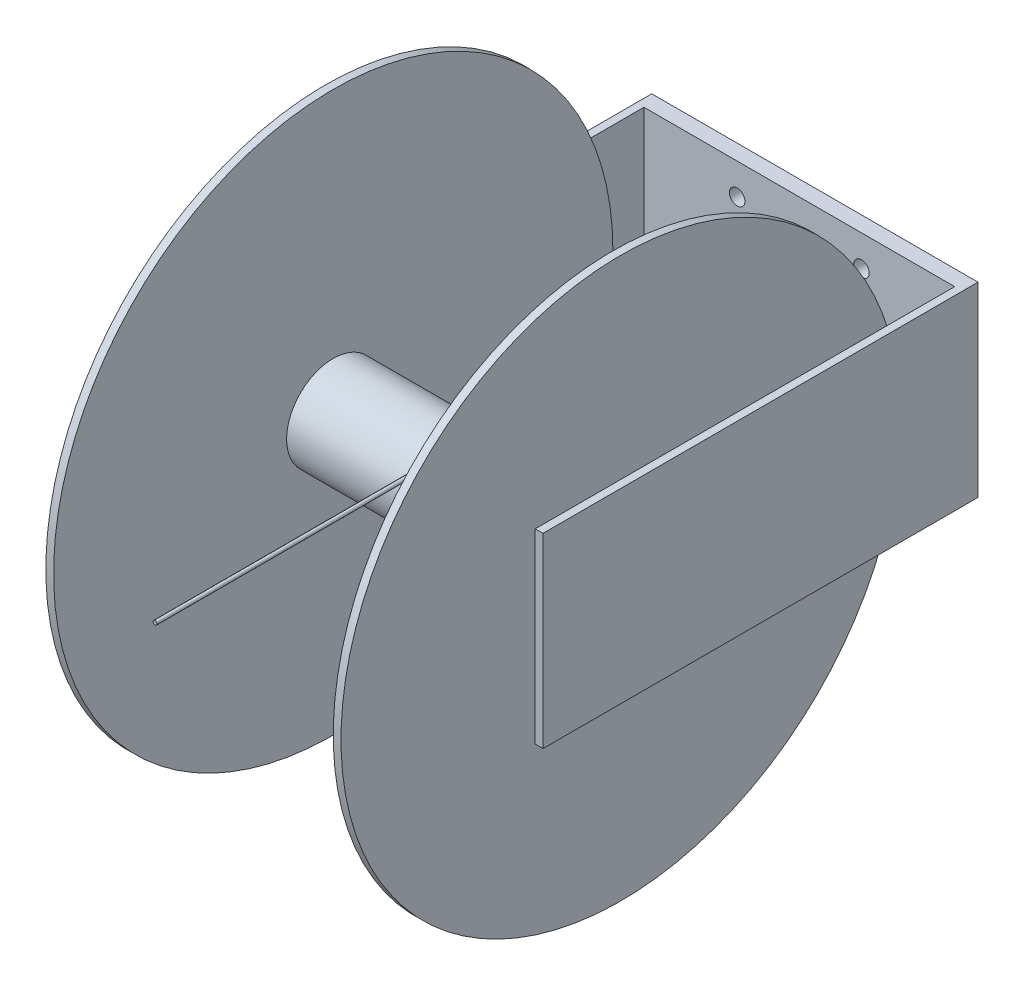
from build123d import *

# Parameters (mm, degrees)
SKETCH1_R           = 228.6
BOSS_EXTRUDE1_DEPTH = 6.35
SKETCH2_R           = 38.1
BOSS_EXTRUDE2_DEPTH = 228.6
SKETCH3_R           = 228.6
BOSS_EXTRUDE3_DEPTH = 6.35
SKETCH4_R           = 38.1
BOSS_EXTRUDE4_DEPTH = 6.35
SKETCH5_R           = 38.1
BOSS_EXTRUDE5_DEPTH = 6.35
BOSS_EXTRUDE6_DEPTH = 6.35
SKETCH7_W           = 203.2
SKETCH7_H           = 152.4
BOSS_EXTRUDE7_DEPTH = 6.35
BOSS_EXTRUDE8_DEPTH = 6.35
SKETCH9_W           = 12.7
SKETCH9_H           = 151.635108104
BOSS_EXTRUDE9_DEPTH = 254
SKETCH10_R          = 6.35
CUT_EXTRUDE1_DEPTH  = 12.7
SKETCH13_R          = 1.59


with BuildPart() as part:
    # Sketch1 → Boss-Extrude1 (new body)
    with BuildSketch(Plane(origin=(0, 0, 0), x_dir=(0, 0, -1), z_dir=(1, 0, 0))):
        Circle(SKETCH1_R)
    extrude(amount=BOSS_EXTRUDE1_DEPTH)

    # Sketch2 → Boss-Extrude2 (add)
    with BuildSketch(Plane(origin=(6.35, 0, 0), x_dir=(0, 0, -1), z_dir=(1, 0, 0))):
        Circle(SKETCH2_R)
    extrude(amount=BOSS_EXTRUDE2_DEPTH)

    # Sketch3 → Boss-Extrude3 (add)
    with BuildSketch(Plane(origin=(234.95, 0, 0), x_dir=(0, 0, -1), z_dir=(1, 0, 0))):
        Circle(SKETCH3_R)
    extrude(amount=BOSS_EXTRUDE3_DEPTH)

    # Sketch4 → Boss-Extrude4 (add)
    with BuildSketch(Plane(origin=(241.3, 0, 0), x_dir=(0, 0, -1), z_dir=(1, 0, 0))):
        Circle(SKETCH4_R)
    extrude(amount=BOSS_EXTRUDE4_DEPTH)

    # Sketch5 → Boss-Extrude5 (add)
    with BuildSketch(Plane.ZY):
        Circle(SKETCH5_R)
    extrude(amount=BOSS_EXTRUDE5_DEPTH)

    # Sketch6 → Boss-Extrude6 (add)
    with BuildSketch(Plane(origin=(247.65, 0, 0), x_dir=(0, 0, -1), z_dir=(1, 0, 0))):
        Polygon((-76.2, -76.2), (-76.2, 0), (-76.2, 76.2), (-5.028509112, 76.2), (76.2, 76.2), (76.2, -76.2), align=None)
    extrude(amount=BOSS_EXTRUDE6_DEPTH)

    # Sketch7 → Boss-Extrude7 (add)
    with BuildSketch(Plane(origin=(254, 0, 0), x_dir=(0, 0, -1), z_dir=(1, 0, 0))):
        with Locations((177.8, 0)):
            Rectangle(SKETCH7_W, SKETCH7_H)
    extrude(amount=-BOSS_EXTRUDE7_DEPTH)

    # Sketch8 → Boss-Extrude8 (add)
    with BuildSketch(Plane.ZY.offset(6.35)):
        Polygon((-76.2, -76.2), (76.2, -76.2), (76.2, 76.2), (-76.2, 76.2), (-279.4, 76.2), (-279.4, -76.2), align=None)
    extrude(amount=BOSS_EXTRUDE8_DEPTH)

    # Sketch9 → Boss-Extrude9 (add)
    with BuildSketch(Plane.ZY.offset(-247.65)):
        with Locations((-273.05, 0.382445948)):
            Rectangle(SKETCH9_W, SKETCH9_H)
    extrude(amount=BOSS_EXTRUDE9_DEPTH)

    # Sketch10 → Cut-Extrude1 (cut)
    with BuildSketch(Plane(origin=(0, 0, -279.4), x_dir=(-1, 0, 0), z_dir=(0, 0, -1))):
        with Locations((-171.45, 50.8)):
            Circle(SKETCH10_R)
        with Locations((-69.85, 50.8)):
            Circle(SKETCH10_R)
        with Locations((-69.85, -50.8)):
            Circle(SKETCH10_R)
        with Locations((-171.45, -50.8)):
            Circle(SKETCH10_R)
    extrude(amount=-CUT_EXTRUDE1_DEPTH, mode=Mode.SUBTRACT)

    # Sweep1: sweep along a path in Sketch12
    with BuildLine(Plane.ZY.offset(-120.65)) as sweep1_path:
        Line((260, 38.1), (0, 38.1))
        ThreePointArc((0, 38.1), (-26.940768363, 26.940768363), (-38.1, 0))
    # Sketch13 → Sweep1 (sweep)
    with BuildSketch(Plane(origin=(0, 0, 0), x_dir=(1, 0, 0), z_dir=(0, 1, 0))):
        with Locations((120.65, 38.1)):
            Circle(SKETCH13_R)
    sweep(path=sweep1_path.line)


solid = part.part
